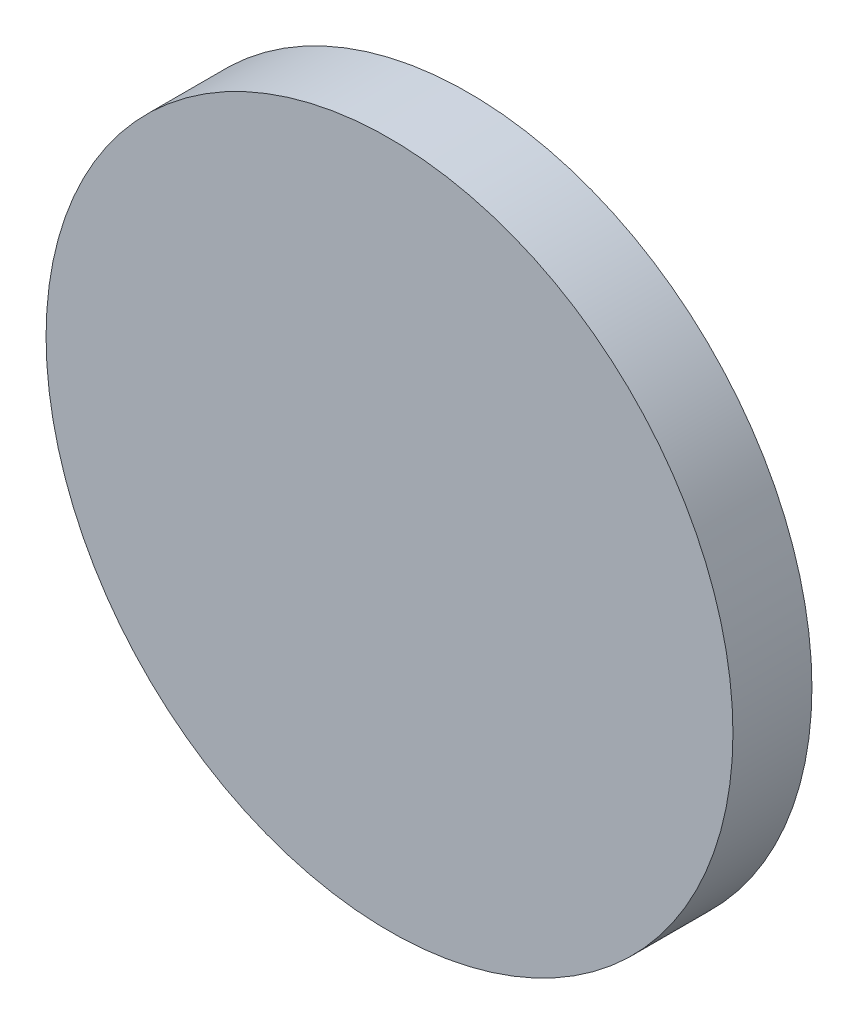
from build123d import *

# Parameters (mm, degrees)
SKETCH_1_R      = 9.999999999
EXTRUDE_1_DEPTH = 2.3


with BuildPart() as part:
    # 草图1 → 凸台-拉伸1 (new body)
    with BuildSketch(Plane.XY):
        with Locations((72.409989288, 41.042161219)):
            Circle(SKETCH_1_R)
    extrude(amount=EXTRUDE_1_DEPTH)


solid = part.part
